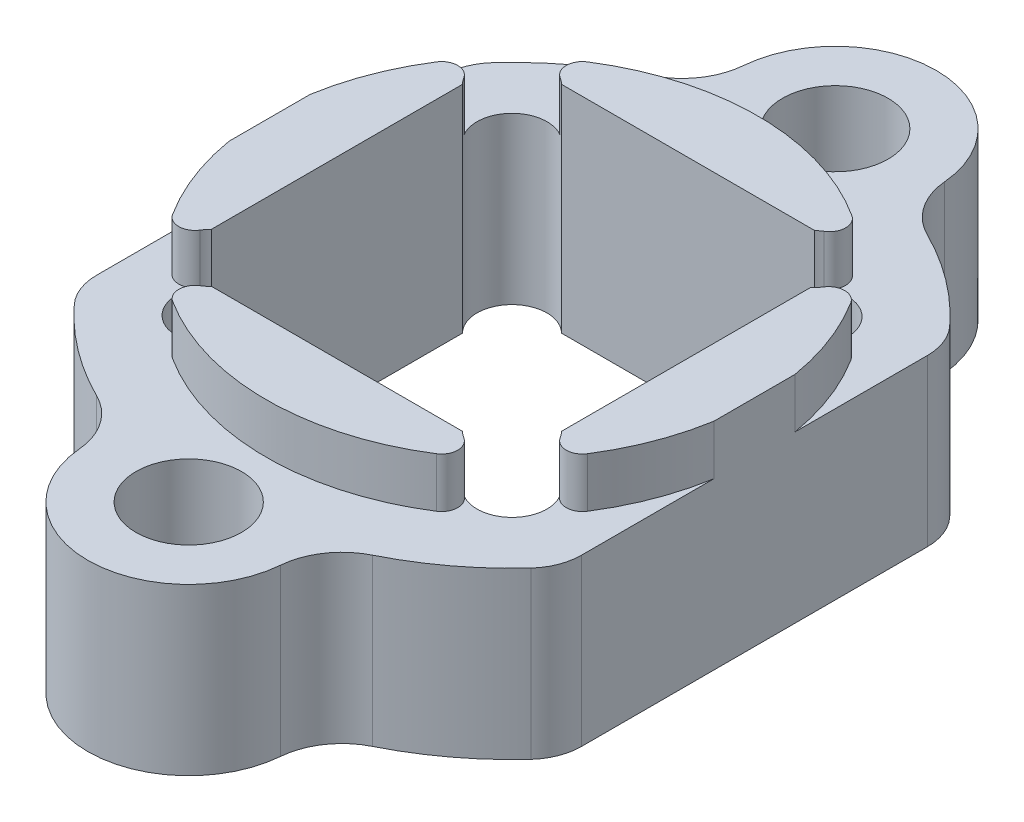
from build123d import *

# Parameters (mm, degrees)
SKETCH1_R           = 2.4892
SKETCH1_W           = 16.49984
SKETCH1_H           = 16.49984
BOSS_EXTRUDE1_DEPTH = 5.08
CUT_EXTRUDE1_DEPTH  = 11.16
SKETCH4_R           = 20.0025
SKETCH4_R_2         = 11.58875
CUT_EXTRUDE2_DEPTH  = 2.3495
SKETCH6_R           = 1.651
CUT_EXTRUDE3_DEPTH  = 11.16
FILLET1_R           = 0.762
FILLET2_R           = 3.175
FILLET3_R           = 2.54


with BuildPart() as part:
    # Sketch1 → Boss-Extrude1 (new body, symmetric)
    with BuildSketch(Plane(origin=(0, 0, 0), x_dir=(1, 0, 0), z_dir=(0, 1, 0))):
        with BuildLine():
            ThreePointArc((-4.56242174, 13.874088542), (0, 20.0025), (4.56242174, 13.874088542))
            ThreePointArc((4.56242174, 13.874088542), (14.605, 0), (4.56242174, -13.874088542))
            ThreePointArc((4.56242174, -13.874088542), (0, -20.0025), (-4.56242174, -13.874088542))
            ThreePointArc((-4.56242174, -13.874088542), (-14.605, 0), (-4.56242174, 13.874088542))
        make_face()
        with Locations((0, 15.24)):
            Circle(SKETCH1_R, mode=Mode.SUBTRACT)
        with Locations((0, -15.24)):
            Circle(SKETCH1_R, mode=Mode.SUBTRACT)
        Rectangle(SKETCH1_W, SKETCH1_H, mode=Mode.SUBTRACT)
    extrude(amount=BOSS_EXTRUDE1_DEPTH, both=True)

    # Sketch2 → Cut-Extrude1 (cut, through all)
    with BuildSketch(Plane(origin=(0, 5.08, 0), x_dir=(1, 0, 0), z_dir=(0, 1, 0))):
        with BuildLine():
            Line((-11.43, -9.091816375), (-11.43, 9.091816375))
            ThreePointArc((-11.43, 9.091816375), (-14.605, 0), (-11.43, -9.091816375))
        make_face()
        with BuildLine():
            Line((11.43, -9.091816375), (11.43, 9.091816375))
            ThreePointArc((11.43, 9.091816375), (14.605, 0), (11.43, -9.091816375))
        make_face()
    extrude(amount=-CUT_EXTRUDE1_DEPTH, mode=Mode.SUBTRACT)

    # Sketch4 → Cut-Extrude2 (cut)
    with BuildSketch(Plane(origin=(0, 5.08, 0), x_dir=(1, 0, 0), z_dir=(0, 1, 0))):
        Circle(SKETCH4_R)
        Circle(SKETCH4_R_2, mode=Mode.SUBTRACT)
    extrude(amount=-CUT_EXTRUDE2_DEPTH, mode=Mode.SUBTRACT)

    # Sketch6 → Cut-Extrude3 (cut, through all)
    with BuildSketch(Plane(origin=(0, 5.08, 0), x_dir=(1, 0, 0), z_dir=(0, 1, 0))):
        with Locations((-7.082486704, 7.082486704)):
            Circle(SKETCH6_R)
        with Locations((7.135507627, 7.031771379)):
            Circle(SKETCH6_R)
        with Locations((7.082486704, -7.082486704)):
            Circle(SKETCH6_R)
        with Locations((-7.078544383, -7.086442383)):
            Circle(SKETCH6_R)
    extrude(amount=-CUT_EXTRUDE3_DEPTH, mode=Mode.SUBTRACT)

    # Fillet1
    fillet1_edges = [part.edges().sort_by_distance(p)[0] for p in [
        (-8.567823829, 3.90525, -7.803301954),
        (7.861200497, 3.90525, -8.514731547),
        (7.803301954, 3.90525, 8.567823829),
        (-7.798496392, 3.90525, 8.572198119),
        (-8.563496345, 3.90525, 7.808050776),
        (8.567823829, 3.90525, 7.803301954),
        (8.628935612, 3.90525, -7.735670415),
        (-7.803301954, 3.90525, -8.567823829),
    ]]
    fillet(fillet1_edges, radius=FILLET1_R)

    # Fillet2
    fillet2_edges = [part.edges().sort_by_distance(p)[0] for p in [
        (-4.56242174, -1.17475, -13.874088542),
        (4.56242174, -1.17475, -13.874088542),
        (4.56242174, -1.17475, 13.874088542),
        (-4.56242174, -1.17475, 13.874088542),
    ]]
    fillet(fillet2_edges, radius=FILLET2_R)

    # Fillet3
    fillet3_edges = [part.edges().sort_by_distance(p)[0] for p in [
        (-11.43, -1.17475, 9.091816375),
        (-11.43, -1.17475, -9.091816375),
        (11.43, -1.17475, -9.091816375),
        (11.43, -1.17475, 9.091816375),
    ]]
    fillet(fillet3_edges, radius=FILLET3_R)


solid = part.part
